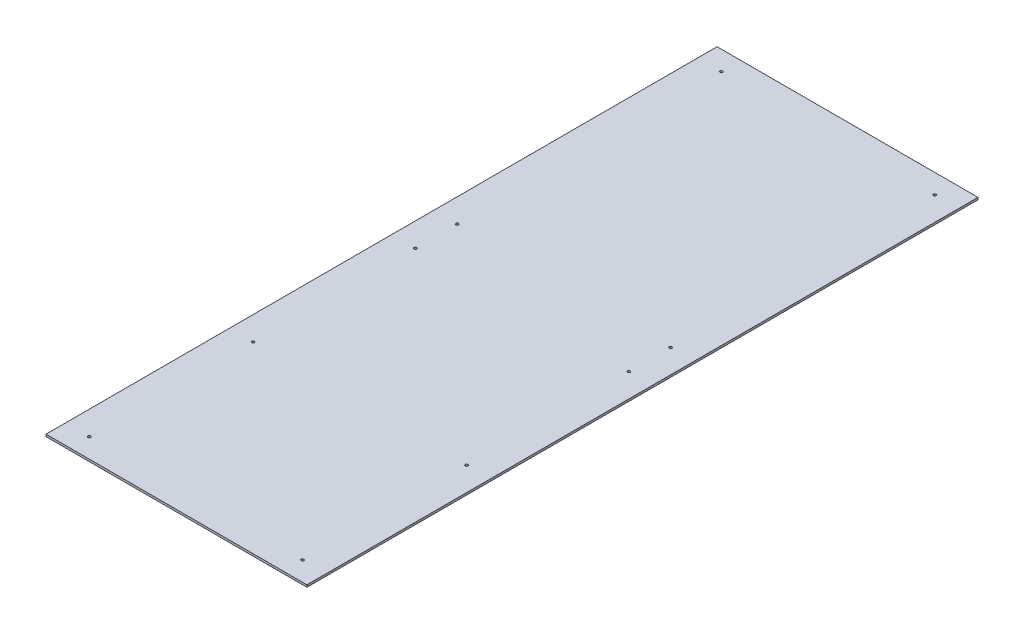
from build123d import *

# Parameters (mm, degrees)
SKETCH1_W                = 767.842
SKETCH1_H                = 1974.85
BOSS_EXTRUDE1_DEPTH      = 6.35
J_0_277_DIAMETER_HOLE1_D = 8.0264


with BuildPart() as part:
    # Sketch1 → Boss-Extrude1 (new body)
    with BuildSketch(Plane(origin=(0, 0, 0), x_dir=(1, 0, 0), z_dir=(0, 1, 0))):
        Rectangle(SKETCH1_W, SKETCH1_H)
    extrude(amount=BOSS_EXTRUDE1_DEPTH)

    # J (0.277) Diameter Hole1 (through all)
    with Locations(Plane(origin=(0, 0, 0), x_dir=(-1, 0, 0), z_dir=(0, -1, 0))):
        with Locations((-314.071, -930.275), (313.944, -930.275), (-314.071, 29.633738777), (314.071, 29.633738777), (313.944, 930.275), (-314.071, 930.275), (-314.071, 152.769407652), (314.071, 152.769407652), (-314.071, -447.611159485), (314.071, -447.611159485)):
            Hole(J_0_277_DIAMETER_HOLE1_D / 2)


solid = part.part
